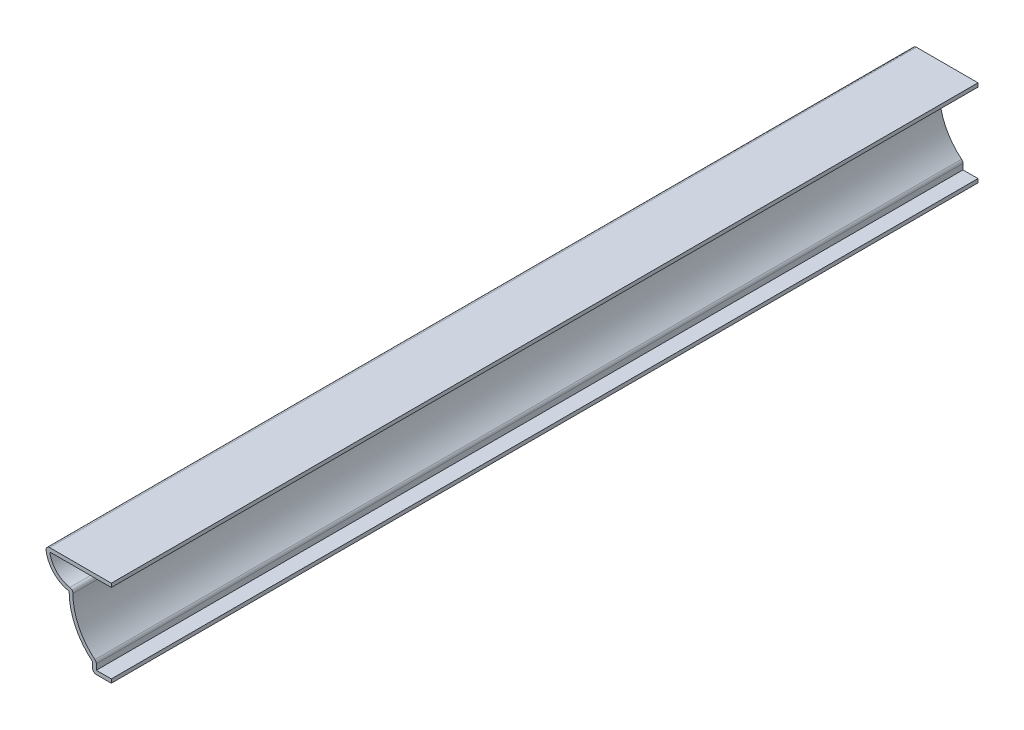
from build123d import *

# Parameters (mm, degrees)
EXTRUDE_THIN1_DEPTH = 293.6875
FILLET1_R           = 1.27


with BuildPart() as part:
    # Sketch1 → Extrude-Thin1 (new body)
    with BuildSketch(Plane.XY):
        with BuildLine():
            Line((0, 0), (-6.35, 0))
            Line((-6.35, 0), (-6.35, 3.175))
            ThreePointArc((-6.35, 3.175), (-12.201824271, 10.612672966), (-14.2875, 19.84375))
            ThreePointArc((-14.2875, 19.84375), (-19.980512816, 23.16936432), (-22.225, 29.36875))
            Line((-22.225, 29.36875), (0, 29.36875))
            Line((0, 29.36875), (0, 28.09875))
            Line((0, 28.09875), (-20.85859868, 28.09875))
            ThreePointArc((-20.85859868, 28.09875), (-18.190231509, 23.133351298), (-12.986259744, 20.966776697))
            ThreePointArc((-12.986259744, 20.966776697), (-11.166701411, 11.396840635), (-5.08, 3.791149695))
            Line((-5.08, 3.791149695), (-5.08, 1.27))
            Line((-5.08, 1.27), (0, 1.27))
            Line((0, 1.27), (0, 0))
        make_face()
    extrude(amount=-EXTRUDE_THIN1_DEPTH)

    # Fillet1
    fillet1_edges = [part.edges().sort_by_distance(p)[0] for p in [
        (-12.986259744, 20.966776697, -146.84375),
        (-5.08, 3.791149695, -146.84375),
        (-6.35, 0, -146.84375),
        (-22.225, 29.36875, -146.84375),
    ]]
    fillet(fillet1_edges, radius=FILLET1_R)


solid = part.part
